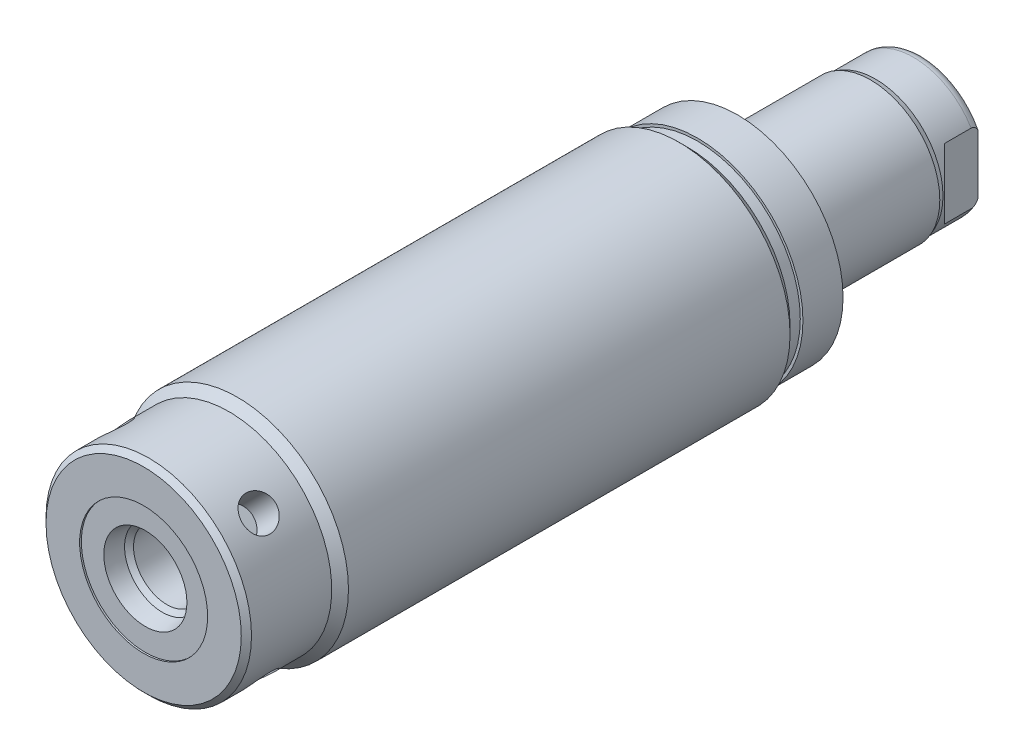
from build123d import *

# Parameters (mm, degrees)
SKETCH1_R          = 16.5354
EXTRUDE1_DEPTH     = 82.423
CHAMFER1_SIZE      = 0.762
SKETCH6_R          = 15.6845
EXTRUDE2_DEPTH     = 5.969
SKETCH7_W          = 27.178
SKETCH7_H          = 10.31875
CUT_EXTRUDE4_DEPTH = 19.84248
HOLE1_D            = 5.0038
HOLE1_DEPTH        = 4.7498
CIRPATTERN1_COUNT  = 4


with BuildPart() as part:
    # Sketch1 → Extrude1 (new body)
    with BuildSketch(Plane.XY):
        Circle(SKETCH1_R)
    extrude(amount=EXTRUDE1_DEPTH)

    # Sketch2 → Cut-Revolve1 (revolve, cut)
    with BuildSketch(Plane(origin=(0, 0, 0), x_dir=(1, 0, 0), z_dir=(0, 1, 0)), mode=Mode.PRIVATE) as cut_revolve1_sk:
        Polygon((16.5354, -82.423), (16.5354, -68.4784), (15.2908, -69.723), (15.2908, -82.423), align=None)
    revolve(cut_revolve1_sk.sketch.rotate(Axis((0, 0, 0), (0, 0, 1)), 180), axis=Axis((0, 0, 0), (0, 0, 1)), mode=Mode.SUBTRACT)  # turned: the seam where the file's is

    # Sketch3 → Cut-Revolve2 (revolve, cut)
    with BuildSketch(Plane(origin=(0, 0, 0), x_dir=(1, 0, 0), z_dir=(0, 1, 0)), mode=Mode.PRIVATE) as cut_revolve2_sk:
        Polygon((15.2908, 0), (15.2908, -1.524), (16.5354, -2.7686), (16.5354, 0), align=None)
    revolve(cut_revolve2_sk.sketch.rotate(Axis((0, 0, 0), (0, 0, -1)), 180), axis=Axis((0, 0, 0), (0, 0, -1)), mode=Mode.SUBTRACT)  # turned: the seam where the file's is

    # S2D0002 → Cut-Revolve3 (revolve, cut)
    with BuildSketch(Plane(origin=(0, 0, 0), x_dir=(1, 0, 0), z_dir=(0, 1, 0))):
        Polygon((6.1849, -82.169), (9.525, -82.169), (9.525, -82.423), (0, -82.423), (0, -68.199), (4.9784, -68.199), (4.9784, -78.952393135), (5.642306865, -79.6163), align=None)
    revolve(axis=Axis((0, 0, 14.6685), (0, 0, -1)), mode=Mode.SUBTRACT)

    # Chamfer1
    chamfer1_edges = [part.edges().sort_by_distance(p)[0] for p in [
        (15.2908, 0, 82.423),
    ]]
    chamfer(chamfer1_edges, length=CHAMFER1_SIZE)

    # Sketch6 → Extrude2 (add)
    with BuildSketch(Plane(origin=(0, 0, 0), x_dir=(-1, 0, 0), z_dir=(0, 0, -1))):
        Circle(SKETCH6_R)
    extrude(amount=EXTRUDE2_DEPTH)

    # Sketch7 → Revolve1 (revolve)
    with BuildSketch(Plane(origin=(0, 0, 0), x_dir=(0, 0, -1), z_dir=(1, 0, 0)), mode=Mode.PRIVATE) as revolve1_sk:
        with Locations((19.558, -5.159375)):
            Rectangle(SKETCH7_W, SKETCH7_H)
    revolve(revolve1_sk.sketch.rotate(Axis((0, 0, 0), (0, 0, -1)), 270), axis=Axis((0, 0, 0), (0, 0, -1)))  # turned: the seam where the file's is

    # S2D0001 → Cut-Revolve5 (revolve, cut)
    with BuildSketch(Plane(origin=(0, 0, 0), x_dir=(1, 0, 0), z_dir=(0, 1, 0))):
        Polygon((3.2639, 31.211260017), (3.2639, 18.2118), (0, 18.2118), (0, 33.147), (4.3815, 33.147), align=None)
    revolve(axis=Axis((0, 0, 31.308359971), (0, 0, -1)), mode=Mode.SUBTRACT)

    # Sketch9 → Cut-Revolve6 (revolve, cut)
    with BuildSketch(Plane(origin=(0, 0, 0), x_dir=(0, -1, 0), z_dir=(1, 0, 0)), mode=Mode.PRIVATE) as cut_revolve6_sk:
        with BuildLine():
            Line((-10.31875, 25.7302), (-10.033, 26.4922))
            Line((-10.033, 26.4922), (-10.033, 32.131))
            ThreePointArc((-10.033, 32.131), (-9.932678675, 32.674796865), (-9.644922533, 33.147))
            Line((-9.644922533, 33.147), (-10.31875, 33.147))
            Line((-10.31875, 33.147), (-10.31875, 25.7302))
        make_face()
    revolve(cut_revolve6_sk.sketch.rotate(Axis((0, 0, -12.65936), (0, 0, -1)), 90), axis=Axis((0, 0, -12.65936), (0, 0, -1)), mode=Mode.SUBTRACT)  # turned: the seam where the file's is

    # Sketch13 → Cut-Extrude4 (cut, symmetric)
    with BuildSketch(Plane(origin=(0, 0, 0), x_dir=(1, 0, 0), z_dir=(0, 1, 0))):
        Polygon((8.5852, 33.147), (8.5852, 28.194), (10.033, 26.7462), (10.033, 33.147), align=None)
        Polygon((-8.5852, 33.147), (-8.5852, 28.194), (-10.033, 26.7462), (-10.033, 33.147), align=None)
    extrude(amount=CUT_EXTRUDE4_DEPTH, both=True, mode=Mode.SUBTRACT)

    # Hole1
    with Locations(Plane(origin=(-10.81222837, 10.81222837, 76.073), x_dir=(0.707106781, 0.707106781, 0), z_dir=(-0.707106781, 0.707106781, 0))):
        with Locations((0, 0)):
            hole1 = Hole(HOLE1_D / 2, depth=HOLE1_DEPTH)

    # CirPattern1: Hole1 ×4 about axis
    cirpattern1_axis = Axis((0, 0, 0), (0, 0, 1))
    for i in range(1, CIRPATTERN1_COUNT):
        add(hole1.rotate(cirpattern1_axis, i * 360 / CIRPATTERN1_COUNT), mode=Mode.SUBTRACT)


solid = part.part
